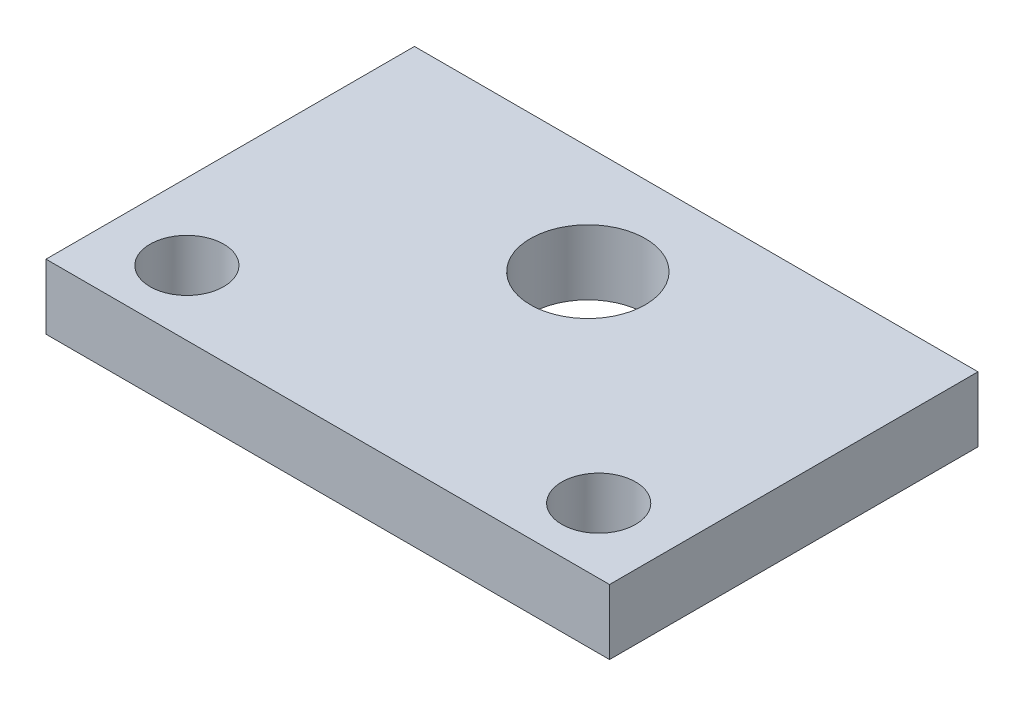
from build123d import *

# Parameters (mm, degrees)
ESBO_O1_W                = 26
ESBO_O1_H                = 17
ESBO_O1_R                = 2.65
RESSALTO_EXTRUS_O1_DEPTH = 3
ESBO_O2_R                = 1.7
CORTE_EXTRUS_O1_DEPTH    = 10


with BuildPart() as part:
    # Esboço1 → Ressalto-extrusão1 (new body)
    with BuildSketch(Plane(origin=(0, 0, 0), x_dir=(1, 0, 0), z_dir=(0, 1, 0))):
        with Locations((13, 8.5)):
            Rectangle(ESBO_O1_W, ESBO_O1_H)
        with Locations((13, 12)):
            Circle(ESBO_O1_R, mode=Mode.SUBTRACT)
    extrude(amount=RESSALTO_EXTRUS_O1_DEPTH)

    # Esboço2 → Corte-extrusão1 (cut)
    with BuildSketch(Plane(origin=(0, 3, 0), x_dir=(1, 0, 0), z_dir=(0, 1, 0))):
        with Locations((3.5, 3)):
            Circle(ESBO_O2_R)
        with Locations((22.5, 3)):
            Circle(ESBO_O2_R)
    extrude(amount=-CORTE_EXTRUS_O1_DEPTH, mode=Mode.SUBTRACT)


solid = part.part
